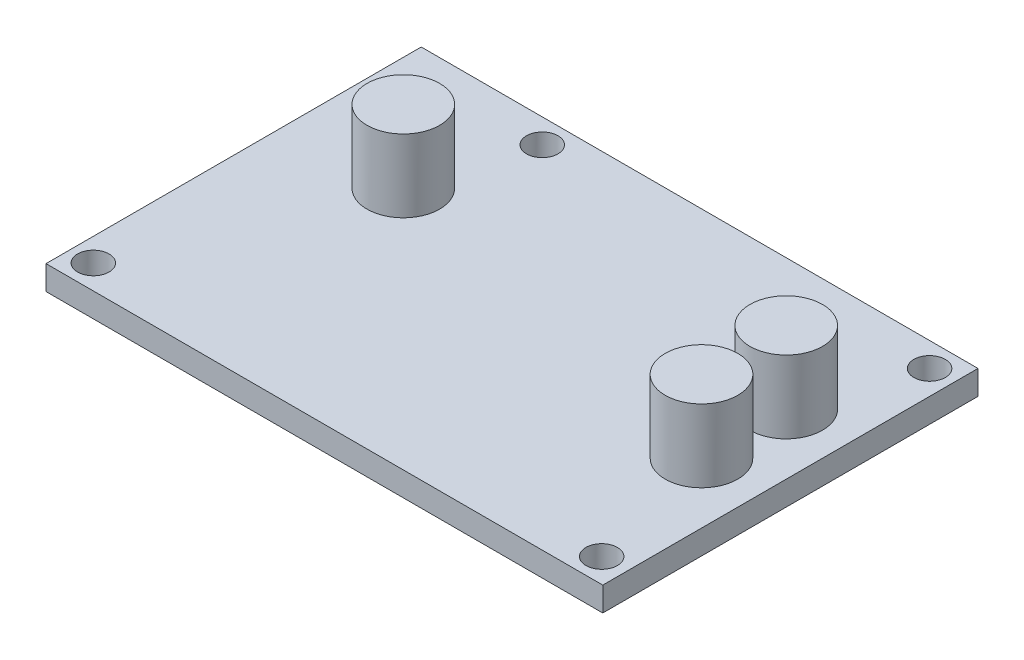
from build123d import *

# Parameters (mm, degrees)
SKETCH1_W           = 58.42
SKETCH1_H           = 39.37
BOSS_EXTRUDE1_DEPTH = 2.54
CUT_EXTRUDE1_REACH  = 4.54
SKETCH2_R           = 1.651
SKETCH2_R_2         = 1.651000008
SKETCH3_R           = 3.81
BOSS_EXTRUDE2_DEPTH = 7.62


with BuildPart() as part:
    # Sketch1 → Boss-Extrude1 (new body)
    with BuildSketch(Plane(origin=(0, 0, 0), x_dir=(1, 0, 0), z_dir=(0, 1, 0))):
        with Locations((29.21, 19.685)):
            Rectangle(SKETCH1_W, SKETCH1_H)
    extrude(amount=BOSS_EXTRUDE1_DEPTH)

    # Sketch2 → Cut-Extrude1 (cut, up to next)
    with BuildSketch(Plane(origin=(0, 2.54, 0), x_dir=(1, 0, 0), z_dir=(0, 1, 0)), mode=Mode.PRIVATE) as cut_extrude1_sk1:
        with Locations((2.4247094, 2.54)):
            Circle(SKETCH2_R)
    cut_extrude1_tool1 = extrude(cut_extrude1_sk1.sketch, amount=-CUT_EXTRUDE1_REACH, mode=Mode.PRIVATE) & part.part
    add(cut_extrude1_tool1.solids().sort_by_distance((2.424709, 2.54, -2.54))[0], mode=Mode.SUBTRACT)
    # Sketch2 → Cut-Extrude1 (cut, up to next)
    with BuildSketch(Plane(origin=(0, 2.54, 0), x_dir=(1, 0, 0), z_dir=(0, 1, 0)), mode=Mode.PRIVATE) as cut_extrude1_sk2:
        with Locations((55.7647094, 2.54)):
            Circle(SKETCH2_R)
    cut_extrude1_tool2 = extrude(cut_extrude1_sk2.sketch, amount=-CUT_EXTRUDE1_REACH, mode=Mode.PRIVATE) & part.part
    add(cut_extrude1_tool2.solids().sort_by_distance((55.764709, 2.54, -2.54))[0], mode=Mode.SUBTRACT)
    # Sketch2 → Cut-Extrude1 (cut, up to next)
    with BuildSketch(Plane(origin=(0, 2.54, 0), x_dir=(1, 0, 0), z_dir=(0, 1, 0)), mode=Mode.PRIVATE) as cut_extrude1_sk3:
        with Locations((15.24, 36.83)):
            Circle(SKETCH2_R)
    cut_extrude1_tool3 = extrude(cut_extrude1_sk3.sketch, amount=-CUT_EXTRUDE1_REACH, mode=Mode.PRIVATE) & part.part
    add(cut_extrude1_tool3.solids().sort_by_distance((15.24, 2.54, -36.83))[0], mode=Mode.SUBTRACT)
    # Sketch2 → Cut-Extrude1 (cut, up to next)
    with BuildSketch(Plane(origin=(0, 2.54, 0), x_dir=(1, 0, 0), z_dir=(0, 1, 0)), mode=Mode.PRIVATE) as cut_extrude1_sk4:
        with Locations((55.88, 36.829806183)):
            Circle(SKETCH2_R_2)
    cut_extrude1_tool4 = extrude(cut_extrude1_sk4.sketch, amount=-CUT_EXTRUDE1_REACH, mode=Mode.PRIVATE) & part.part
    add(cut_extrude1_tool4.solids().sort_by_distance((55.88, 2.54, -36.829806))[0], mode=Mode.SUBTRACT)

    # Sketch3 → Boss-Extrude2 (add)
    with BuildSketch(Plane(origin=(0, 2.54, 0), x_dir=(1, 0, 0), z_dir=(0, 1, 0))):
        with Locations((52.07, 25.59786872)):
            Circle(SKETCH3_R)
        with Locations((52.07, 16.70786872)):
            Circle(SKETCH3_R)
        with Locations((11.895013778, 25.59786872)):
            Circle(SKETCH3_R)
    extrude(amount=BOSS_EXTRUDE2_DEPTH)


solid = part.part
